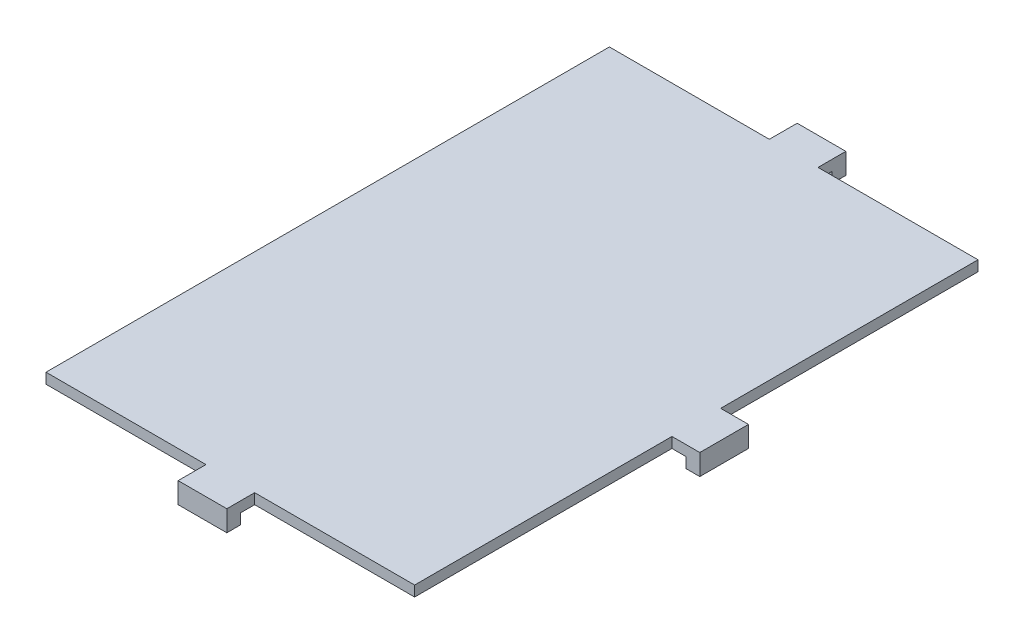
from build123d import *

# Parameters (mm, degrees)
BOSS_EXTRUDE1_DEPTH = 1.5
SKETCH2_W           = 7
SKETCH2_H           = 2
SKETCH2_W_2         = 2
SKETCH2_H_2         = 7
BOSS_EXTRUDE2_DEPTH = 3


with BuildPart() as part:
    # Sketch1 → Boss-Extrude1 (new body)
    with BuildSketch(Plane(origin=(0, 0, 0), x_dir=(1, 0, 0), z_dir=(0, 1, 0))):
        Polygon((30, 81), (53, 81), (53, 44), (55, 44), (55, 37), (53, 37), (53, 0), (30, 0), (30, -2), (23, -2), (23, 0), (0, 0), (0, 81), (23, 81), (23, 83), (30, 83), align=None)
    extrude(amount=BOSS_EXTRUDE1_DEPTH)

    # Sketch2 → Boss-Extrude2 (add)
    with BuildSketch(Plane(origin=(0, 1.5, 0), x_dir=(1, 0, 0), z_dir=(0, 1, 0))):
        with Locations((26.5, 84)):
            Rectangle(SKETCH2_W, SKETCH2_H)
        with Locations((56, 40.5)):
            Rectangle(SKETCH2_W_2, SKETCH2_H_2)
        with Locations((26.5, -3)):
            Rectangle(SKETCH2_W, SKETCH2_H)
    extrude(amount=-BOSS_EXTRUDE2_DEPTH)


solid = part.part
